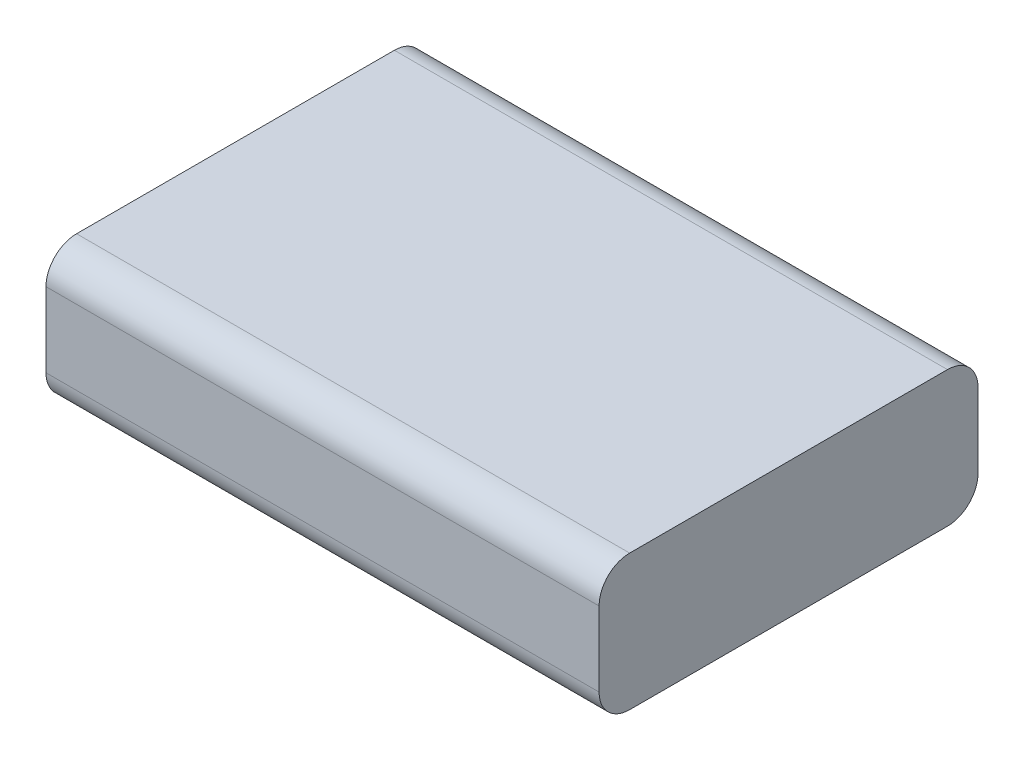
from build123d import *

# Parameters (mm, degrees)
SKETCH1_W           = 90.5
SKETCH1_H           = 62
BOSS_EXTRUDE1_DEPTH = 22.2
FILLET1_R           = 5


with BuildPart() as part:
    # Sketch1 → Boss-Extrude1 (new body)
    with BuildSketch(Plane(origin=(0, 0, 0), x_dir=(1, 0, 0), z_dir=(0, 1, 0))):
        with Locations((45.25, 31)):
            Rectangle(SKETCH1_W, SKETCH1_H)
    extrude(amount=BOSS_EXTRUDE1_DEPTH)

    # Fillet1
    fillet1_edges = [part.edges().sort_by_distance(p)[0] for p in [
        (45.25, 22.2, -62),
        (45.25, 0, -62),
        (45.25, 0, 0),
        (45.25, 22.2, 0),
    ]]
    fillet(fillet1_edges, radius=FILLET1_R)


solid = part.part
